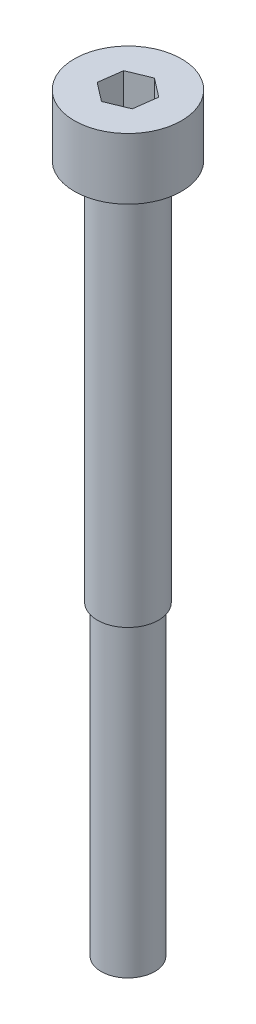
from build123d import *

# Parameters (mm, degrees)
SKETCH_1_R          = 2
EXTRUDE_1_DEPTH     = 25
SKETCH_1_3_R        = 1.75
EXTRUDE_2_DEPTH     = 20
SKETCH_2_R          = 3.5
EXTRUDE_3_DEPTH     = 4
CUT_EXTRUDE_1_DEPTH = 3


with BuildPart() as part:
    # 草图1 → 凸台-拉伸1 (new body)
    with BuildSketch(Plane(origin=(0, 0, 0), x_dir=(1, 0, 0), z_dir=(0, 1, 0))):
        Circle(SKETCH_1_R)
    extrude(amount=EXTRUDE_1_DEPTH)

    # 草图1<3> → 凸台-拉伸2 (add)
    with BuildSketch(Plane(origin=(0, 0, 0), x_dir=(1, 0, 0), z_dir=(0, 1, 0))):
        Circle(SKETCH_1_3_R)
    extrude(amount=-EXTRUDE_2_DEPTH)

    # 草图2 → 凸台-拉伸3 (add)
    with BuildSketch(Plane(origin=(0, 25, 0), x_dir=(1, 0, 0), z_dir=(0, 1, 0))):
        Circle(SKETCH_2_R)
    extrude(amount=EXTRUDE_3_DEPTH)

    # 草图3 → 切除-拉伸1 (cut)
    with BuildSketch(Plane(origin=(0, 29, 0), x_dir=(1, 0, 0), z_dir=(0, 1, 0))):
        Polygon((1.22041658, -0.939246172), (1.423619335, 0.587288675), (0.203202756, 1.526534847), (-1.22041658, 0.939246172), (-1.423619335, -0.587288675), (-0.203202756, -1.526534847), align=None)
    extrude(amount=-CUT_EXTRUDE_1_DEPTH, mode=Mode.SUBTRACT)


solid = part.part
